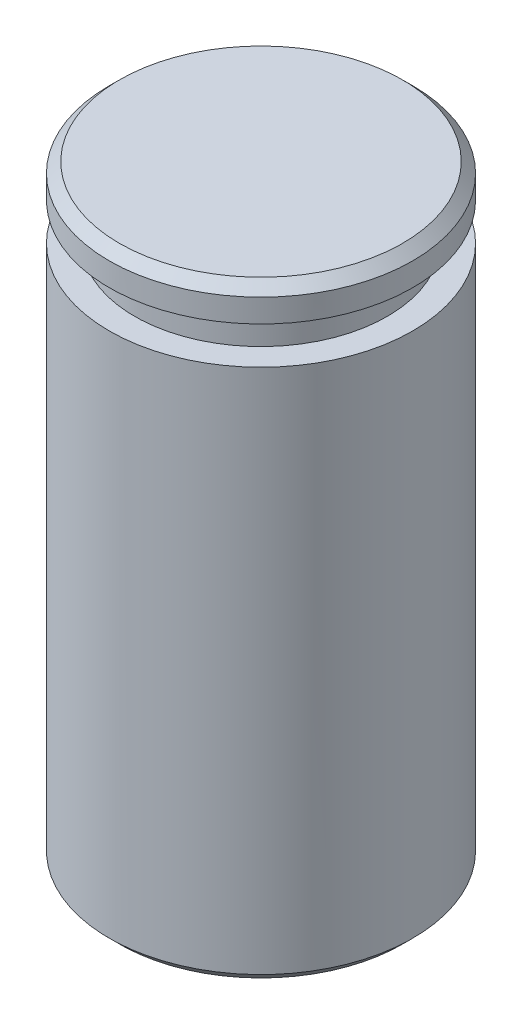
from build123d import *

# Parameters (mm, degrees)
SKETCH1_W       = 3
SKETCH1_H       = 12
SKETCH5_W       = 2.05
SKETCH5_H       = 0.74
CHANFREIN1_SIZE = 0.2


with BuildPart() as part:
    # Sketch1 → Revolve1 (revolve)
    with BuildSketch(Plane.XY):
        with Locations((1.5, 6)):
            Rectangle(SKETCH1_W, SKETCH1_H)
    revolve(axis=Axis((0, 0, 0), (0, 1, 0)))

    # Sketch5 → Groove for DIN 471 - 4 x 0.4, Circlip for shafts - normal1 (revolve, cut)
    with BuildSketch(Plane(origin=(0, 0, 0), x_dir=(0, 0, -1), z_dir=(-1, 0, 0))):
        with Locations((3.525, -10.97)):
            Rectangle(SKETCH5_W, SKETCH5_H)
    revolve(axis=Axis((0, 50.028808754, 0), (0, -1, 0)), mode=Mode.SUBTRACT)

    # Chanfrein1
    chanfrein1_edges = [part.edges().sort_by_distance(p)[0] for p in [
        (-3, 0, 0),
        (-3, 12, 0),
    ]]
    chamfer(chanfrein1_edges, length=CHANFREIN1_SIZE)


solid = part.part
